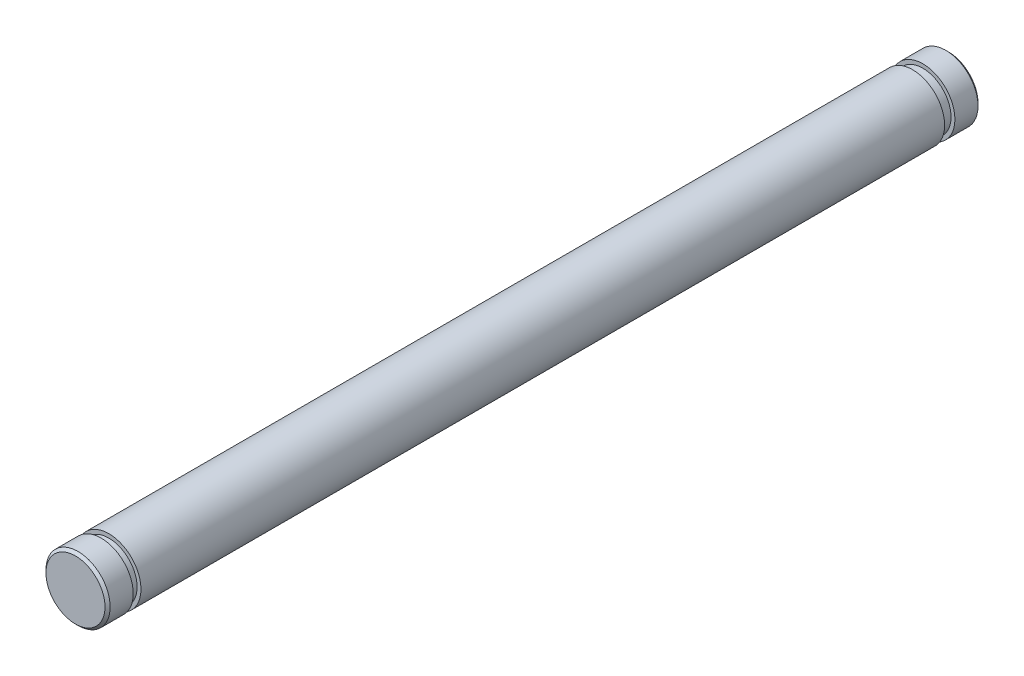
from build123d import *

# Parameters (mm, degrees)
SKETCH_1_R          = 1.25
EXTRUDE_1_DEPTH     = 34
SKETCH_2_R          = 1.25
SKETCH_2_R_2        = 1.1
CUT_EXTRUDE_1_DEPTH = 0.4
SKETCH_3_R          = 1.25
SKETCH_3_R_2        = 1.1
CUT_EXTRUDE_2_DEPTH = 0.3
CHAMFER_1_SIZE      = 0.1


with BuildPart() as part:
    # 草图1 → 凸台-拉伸1 (new body)
    with BuildSketch(Plane.XY):
        Circle(SKETCH_1_R)
    extrude(amount=EXTRUDE_1_DEPTH)

    # 草图2 → 切除-拉伸1 (cut)
    with BuildSketch(Plane.XY.offset(1)):
        Circle(SKETCH_2_R)
        Circle(SKETCH_2_R_2, mode=Mode.SUBTRACT)
    extrude(amount=CUT_EXTRUDE_1_DEPTH, mode=Mode.SUBTRACT)

    # 草图3 → 切除-拉伸2 (cut)
    with BuildSketch(Plane.XY.offset(33)):
        Circle(SKETCH_3_R)
        Circle(SKETCH_3_R_2, mode=Mode.SUBTRACT)
    extrude(amount=-CUT_EXTRUDE_2_DEPTH, mode=Mode.SUBTRACT)

    # 倒角1
    chamfer_1_edges = [part.edges().sort_by_distance(p)[0] for p in [
        (-1.25, 0, 0),
        (-1.25, 0, 34),
    ]]
    chamfer(chamfer_1_edges, length=CHAMFER_1_SIZE)


solid = part.part
